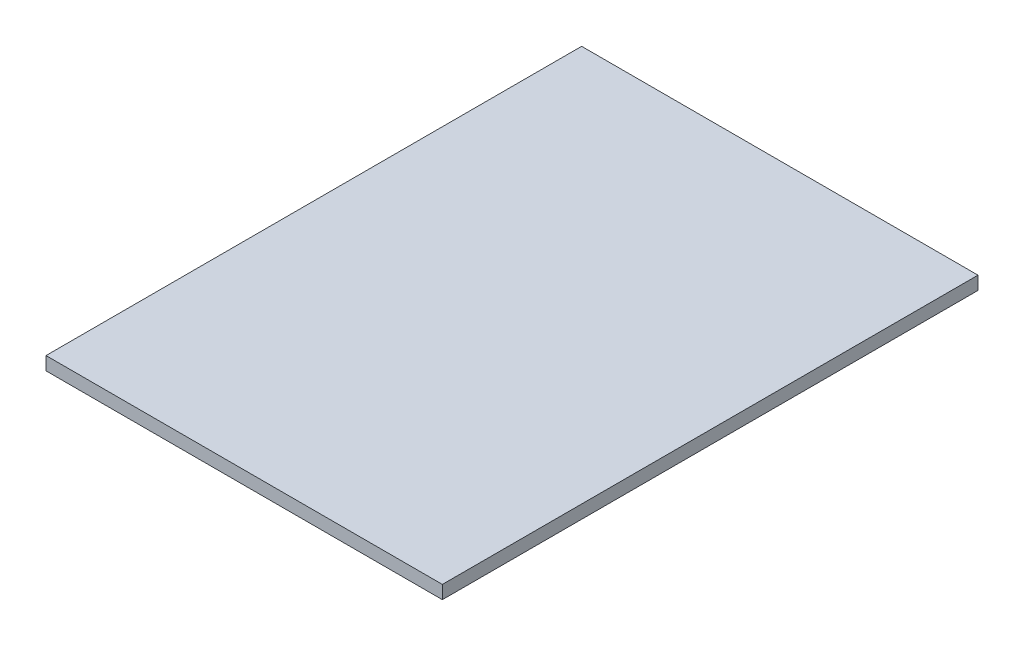
from build123d import *

# Parameters (mm, degrees)
SKETCH1_W           = 357.124
SKETCH1_H           = 482.6
BOSS_EXTRUDE1_DEPTH = 11.938


with BuildPart() as part:
    # Sketch1 → Boss-Extrude1 (new body)
    with BuildSketch(Plane(origin=(0, 0, 0), x_dir=(1, 0, 0), z_dir=(0, 1, 0))):
        Rectangle(SKETCH1_W, SKETCH1_H)
    extrude(amount=BOSS_EXTRUDE1_DEPTH)


solid = part.part
